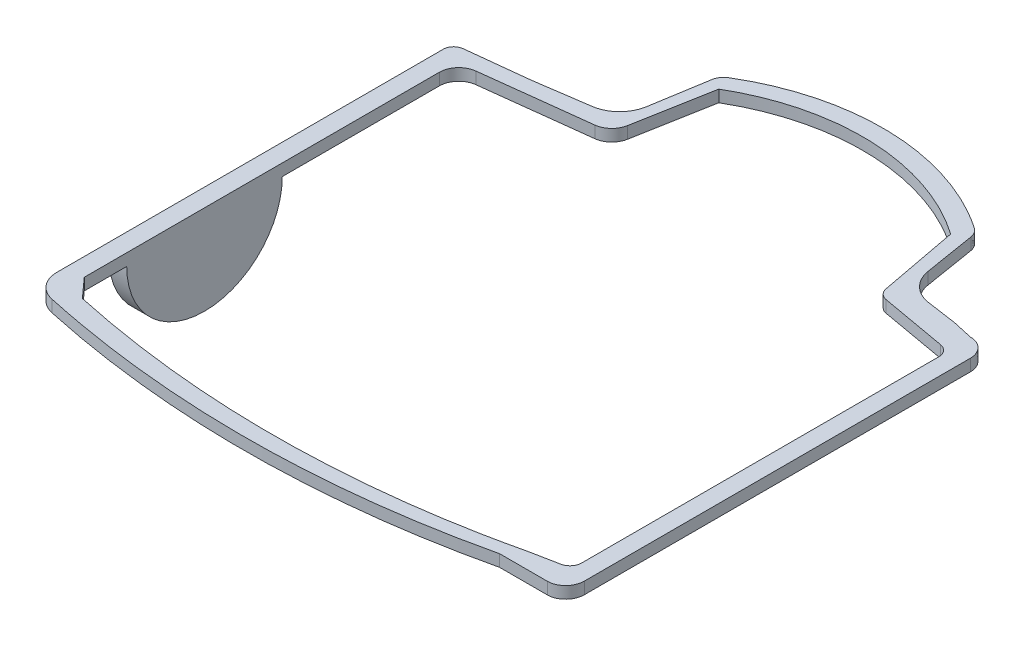
from build123d import *

# Parameters (mm, degrees)
EXTRUDE1_DEPTH    = 3.048
EXTRUDE2_START    = -4.922022
EXTRUDE2_DEPTH    = 4.922022
SKETCH7_OUTSIDE_W = 180.306
SKETCH7_OUTSIDE_H = 194.6
EXTRUDE3_DEPTH    = 66


with BuildPart() as part:
    # Sketch1 → Extrude1 (new body)
    with BuildSketch(Plane(origin=(0, 0, 0), x_dir=(1, 0, 0), z_dir=(0, 1, 0))):
        with BuildLine():
            Line((-68.588225015, -50.447006933), (-68.588225015, -8.447006933))
            Line((-68.588225015, -8.447006933), (-68.588225015, 36.476262533))
            ThreePointArc((-68.588225015, 36.476262533), (-67.823252384, 38.47742536), (-65.918456575, 39.458031658))
            Line((-65.918456575, 39.458031658), (-50.238652077, 41.194573314))
            ThreePointArc((-50.238652077, 41.194573314), (-50.103667096, 41.210697371), (-49.968978913, 41.229137096))
            Line((-49.968978913, 41.229137096), (-36.405212301, 43.204890932))
            add(Edge.make_bspline(
                [(-29.65298493, 49.892180453), (-29.790845033, 49.048800123), (-30.054186091, 48.248422831), (-30.636357931, 47.111997779), (-30.860349594, 46.74871746), (-31.357293164, 46.067804533), (-31.631491773, 45.747658845), (-32.082330248, 45.298656736), (-32.23999217, 45.153607012), (-32.56434492, 44.87828288), (-32.73106827, 44.747841717), (-33.244584245, 44.377712455), (-33.604640908, 44.159088542), (-34.360627861, 43.778810451), (-34.758876947, 43.616878199), (-35.56849202, 43.36152283), (-35.982264945, 43.266499177), (-36.405212301, 43.204890932)],
                knots=[0, 0, 0, 0, 0.25, 0.25, 0.375, 0.375, 0.5, 0.5, 0.5625, 0.5625, 0.625, 0.625, 0.75, 0.75, 0.875, 0.875, 1, 1, 1, 1], degree=3))
            Line((-29.65298493, 49.892180453), (-27.295043857, 64.317246664))
            add(Edge.make_bspline(
                [(-25.398403705, 67.116004585), (-25.649830938, 66.965226012), (-25.880200616, 66.789908757), (-26.300568587, 66.392228876), (-26.492052484, 66.166884769), (-26.817136098, 65.687155628), (-26.952806077, 65.431741016), (-27.169221008, 64.889128082), (-27.24775317, 64.606554695), (-27.295043857, 64.317246664)],
                knots=[0, 0, 0, 0, 0.25, 0.25, 0.5, 0.5, 0.75, 0.75, 1, 1, 1, 1], degree=3))
            add(Edge.make_bspline(
                [(39.946457275, 65.21487163), (37.548346719, 66.848744919), (35.063171769, 68.292658296), (29.92526946, 70.81491379), (27.272527642, 71.893224358), (23.84960363, 73.007663624), (23.159643932, 73.218824356), (21.768814193, 73.617341281), (21.066849207, 73.804928486), (18.960504961, 74.327526345), (17.55147157, 74.623797041), (13.310303393, 75.35995475), (10.464168442, 75.647923544), (6.167019051, 75.776619359), (4.729961072, 75.768790373), (1.846297736, 75.64953214), (0.395242238, 75.53728528), (-3.906620393, 75.048810357), (-6.724065109, 74.522139921), (-12.260788462, 73.077757748), (-14.980069273, 72.160054673), (-18.315815004, 70.760552168), (-18.980393058, 70.46765711), (-20.296101599, 69.859409258), (-20.947996673, 69.543762313), (-22.885867568, 68.562374761), (-24.154051585, 67.862230979), (-25.398403705, 67.116004585)],
                knots=[0, 0, 0, 0, 0.125, 0.125, 0.25, 0.25, 0.28125, 0.28125, 0.3125, 0.3125, 0.375, 0.375, 0.5, 0.5, 0.5625, 0.5625, 0.625, 0.625, 0.75, 0.75, 0.875, 0.875, 0.90625, 0.90625, 0.9375, 0.9375, 1, 1, 1, 1], degree=3))
            add(Edge.make_bspline(
                [(41.64820015, 62.540799755), (41.604039667, 62.810958287), (41.533425164, 63.072041448), (41.341350867, 63.576764675), (41.218012217, 63.823007043), (40.926990246, 64.280858099), (40.760036358, 64.492860302), (40.383155624, 64.882949273), (40.172700886, 65.06072803), (39.946457275, 65.21487163)],
                knots=[0, 0, 0, 0, 0.25, 0.25, 0.5, 0.5, 0.75, 0.75, 1, 1, 1, 1], degree=3))
            Line((41.64820015, 62.540799755), (43.786161784, 49.461491505))
            add(Edge.make_bspline(
                [(50.538389155, 42.774201985), (49.692597751, 42.897403427), (48.889079341, 43.150828046), (47.746268764, 43.723396496), (47.382146665, 43.944235836), (46.69795592, 44.436641493), (46.375910798, 44.709187447), (45.923516022, 45.158306136), (45.777532635, 45.315236658), (45.50087131, 45.637312265), (45.369568312, 45.803013725), (44.996272823, 46.313797506), (44.774768734, 46.672476215), (44.387075083, 47.426541114), (44.221321939, 47.822614875), (43.956171894, 48.627827375), (43.855083908, 49.039849834), (43.786161784, 49.461491505)],
                knots=[0, 0, 0, 0, 0.25, 0.25, 0.375, 0.375, 0.5, 0.5, 0.5625, 0.5625, 0.625, 0.625, 0.75, 0.75, 0.875, 0.875, 1, 1, 1, 1], degree=3))
            Line((50.538389155, 42.774201985), (58.440089637, 41.623207907))
            Line((58.440089637, 41.623207907), (63.588225015, 40.468930958))
            add(Edge.make_bspline(
                [(68.588225015, 35.44224599), (68.588225015, 35.773254316), (68.556021228, 36.098784146), (68.461358552, 36.579192656), (68.422021117, 36.738004749), (68.327424314, 37.052920303), (68.271872128, 37.209534827), (68.084584875, 37.665329204), (67.931722078, 37.953670071), (67.570460552, 38.499570051), (67.359921239, 38.758449119), (66.899556696, 39.222838097), (66.648302998, 39.431296313), (66.102661574, 39.799623667), (65.811118966, 39.956772738), (65.209087651, 40.208769752), (64.894651475, 40.305670054), (64.246771662, 40.436198597), (63.919283432, 40.468930958), (63.588225015, 40.468930958)],
                knots=[0, 0, 0, 0, 0.125, 0.125, 0.1875, 0.1875, 0.25, 0.25, 0.375, 0.375, 0.5, 0.5, 0.625, 0.625, 0.75, 0.75, 0.875, 0.875, 1, 1, 1, 1], degree=3))
            Line((68.588225015, 35.44224599), (68.588218791, -63.754822214))
            add(Edge.make_bspline(
                [(63.588218791, -68.902162312), (63.923306937, -68.902162312), (64.25252025, -68.867855209), (64.899712771, -68.733637518), (65.221180948, -68.631932879), (65.830547879, -68.368331753), (66.119042643, -68.207300566), (66.664058612, -67.827506129), (66.919687763, -67.608228672), (67.377079357, -67.130790475), (67.582113335, -66.870497188), (67.943235276, -66.306577156), (68.093765574, -66.011699483), (68.337870377, -65.39744467), (68.431875057, -65.075082192), (68.556800634, -64.420646043), (68.588218791, -64.089647238), (68.588218791, -63.754822214)],
                knots=[0, 0, 0, 0, 0.125, 0.125, 0.25, 0.25, 0.375, 0.375, 0.5, 0.5, 0.625, 0.625, 0.75, 0.75, 0.875, 0.875, 1, 1, 1, 1], degree=3))
            Line((63.588218791, -68.902162312), (51.32733075, -68.902162312))
            add(Edge.make_bspline(
                [(-63.058226864, -69.750431632), (-53.643280021, -71.800179342), (-44.143561703, -73.319672557), (-24.976642993, -75.311040979), (-15.366883932, -75.776619359), (3.902347458, -75.625508924), (13.476454984, -75.011667248), (32.496305515, -72.745142394), (41.944035583, -71.092627797), (51.32733075, -68.902162312)],
                knots=[0, 0, 0, 0, 0.25, 0.25, 0.5, 0.5, 0.75, 0.75, 1, 1, 1, 1], degree=3))
            add(Edge.make_bspline(
                [(-68.588225015, -62.812922076), (-68.588225015, -63.619702903), (-68.456305975, -64.404084155), (-67.9279771, -65.927936682), (-67.545502278, -66.626025877), (-66.544078761, -67.889406122), (-65.950990154, -68.421382079), (-64.584875646, -69.277063679), (-63.846782984, -69.578753434), (-63.058226864, -69.750431632)],
                knots=[0, 0, 0, 0, 0.25, 0.25, 0.5, 0.5, 0.75, 0.75, 1, 1, 1, 1], degree=3))
            Line((-68.588225015, -62.812922076), (-68.588225015, -50.447006933))
        make_face()
        with BuildLine():
            Line((-63.666203197, -60.439880615), (-63.666203197, -52.176662042))
            Line((-63.666203197, -52.176662042), (-63.666203197, -6.717351825))
            Line((-63.666203197, -6.717351825), (-63.666203197, 30.862484301))
            ThreePointArc((-63.666203197, 30.862484301), (-62.405536347, 34.181729335), (-59.259248158, 35.827189496))
            Line((-59.259248158, 35.827189496), (-31.919097385, 39.093030672))
            ThreePointArc((-31.919097385, 39.093030672), (-29.085376213, 40.416681917), (-27.592483972, 43.165008872))
            Line((-27.592483972, 43.165008872), (-23.987325535, 63.032390503))
            add(Edge.make_bspline(
                [(-23.987325535, 63.032390503), (-22.797133326, 63.729242773), (-21.584758638, 64.38206327), (-19.73306331, 65.295525092), (-19.110304285, 65.589040461), (-17.853691073, 66.154049233), (-17.219092065, 66.425821419), (-15.945235684, 66.9446247), (-15.305425073, 67.191999646), (-14.020083768, 67.662886741), (-13.374553208, 67.886398807), (-11.429450154, 68.521425694), (-10.121366283, 68.897431206), (-7.48286605, 69.556271469), (-6.152449253, 69.839104402), (-4.139838561, 70.192490615), (-3.466137414, 70.298475489), (-2.451309886, 70.439614204), (-2.112321409, 70.483687343), (-1.43291428, 70.565866957), (-1.092495759, 70.603973442), (-0.410223111, 70.674199239), (-0.06809824, 70.706297034), (0.617344562, 70.764409572), (0.960662362, 70.790424325), (1.991227722, 70.859264858), (2.679086985, 70.892886868), (4.050159845, 70.935165523), (4.73442996, 70.944005556), (6.100465355, 70.937342433), (6.782230378, 70.92183922), (10.18485778, 70.784102894), (12.887199026, 70.481908625), (16.240350042, 69.863433501), (16.909736979, 69.727658236), (18.245994002, 69.431652667), (18.912863846, 69.271422459), (20.244057358, 68.926212191), (20.90939076, 68.740879996), (22.22738475, 68.348154347), (22.881076068, 68.140532644), (24.826470511, 67.484389713), (26.102589867, 67.00279619), (28.613650647, 65.952218689), (29.84859206, 65.383234685), (33.492313186, 63.546605715), (35.840002607, 62.149310998), (38.103053994, 60.572391997)],
                knots=[0, 0, 0, 0, 0.0625, 0.0625, 0.09375, 0.09375, 0.125, 0.125, 0.15625, 0.15625, 0.1875, 0.1875, 0.25, 0.25, 0.3125, 0.3125, 0.34375, 0.34375, 0.359375, 0.359375, 0.375, 0.375, 0.390625, 0.390625, 0.40625, 0.40625, 0.4375, 0.4375, 0.46875, 0.46875, 0.5, 0.5, 0.625, 0.625, 0.65625, 0.65625, 0.6875, 0.6875, 0.71875, 0.71875, 0.75, 0.75, 0.8125, 0.8125, 0.875, 0.875, 1, 1, 1, 1], degree=3))
            Line((38.103053994, 60.572391997), (41.989282829, 40.057287174))
            ThreePointArc((41.989282829, 40.057287174), (42.827627821, 38.482317147), (44.412021505, 37.661921165))
            Line((44.412021505, 37.661921165), (61.435143503, 34.637128514))
            ThreePointArc((61.435143503, 34.637128514), (63.209707192, 33.610241672), (63.91030255, 31.683394761))
            Line((63.91030255, 31.683394761), (63.910296789, -60.12270492))
            ThreePointArc((63.910296789, -60.12270492), (63.22803468, -62.02745959), (61.491569593, -63.065853034))
            Line((61.491569593, -63.065853034), (54.228190779, -64.500372852))
            add(Edge.make_bspline(
                [(54.228190779, -64.500372852), (53.646867638, -64.636078726), (53.065379768, -64.770443612), (52.192801078, -64.96916712), (51.9018837, -65.034937653), (51.465408439, -65.132785955), (51.319900153, -65.165267472), (51.028848437, -65.229944419), (50.883305004, -65.262139823), (50.592180927, -65.326227715), (50.446602916, -65.358141641), (50.155414986, -65.421709735), (50.009805064, -65.453363879), (49.572927449, -65.547936812), (49.281611909, -65.610466098), (48.407474105, -65.796497612), (47.824460655, -65.918443491), (44.908121552, -66.517819345), (42.570980339, -66.964188687), (35.547451567, -68.204754667), (30.848958746, -68.900408211), (21.420254, -70.033505383), (16.690042075, -70.47094901), (9.570501221, -70.929926983), (7.19328364, -71.050053101), (2.430697569, -71.223956158), (0.043817097, -71.277740334), (-7.118289251, -71.338556455), (-11.887166083, -71.244653595), (-21.413307491, -70.790490202), (-26.171888338, -70.43010405), (-40.422184613, -68.954109584), (-49.839764859, -67.449410248), (-59.173660294, -65.417308409)],
                knots=[0, 0, 0, 0, 0.015625, 0.015625, 0.0234375, 0.0234375, 0.02734375, 0.02734375, 0.03125, 0.03125, 0.03515625, 0.03515625, 0.0390625, 0.0390625, 0.046875, 0.046875, 0.0625, 0.0625, 0.125, 0.125, 0.25, 0.25, 0.375, 0.375, 0.4375, 0.4375, 0.5, 0.5, 0.625, 0.625, 0.75, 0.75, 1, 1, 1, 1], degree=3))
            Line((-59.173660294, -65.417308409), (-63.666203197, -60.439880615))
        make_face(mode=Mode.SUBTRACT)
    extrude(amount=EXTRUDE1_DEPTH)

    # Sketch5 → Extrude2 (add)
    with BuildSketch(Plane.ZY.offset(68.588225015).offset(EXTRUDE2_START)):
        with BuildLine():
            Line((9.73548029, 2.872755472), (49.320693489, 2.872755472))
            ThreePointArc((49.320693489, 2.872755472), (29.52808689, -20), (9.73548029, 2.872755472))
        make_face()
    extrude(amount=EXTRUDE2_DEPTH)

    # Sketch7 outside → Extrude3 (cut)
    with BuildSketch(Plane(origin=(0, 3.048, 0), x_dir=(1, 0, 0), z_dir=(0, 1, 0))):
        with Locations((0, 0.026)):
            Rectangle(SKETCH7_OUTSIDE_W, SKETCH7_OUTSIDE_H)
        with BuildLine():
            Line((-68.288225015, 36.476262533), (-68.288225015, -62.812922076))
            add(Edge.make_bspline(
                [(-68.288225015, -62.812922076), (-68.288225015, -63.58548994), (-68.161995647, -64.336613523), (-67.656432045, -65.795862362), (-67.290363007, -66.464531085), (-66.331952793, -67.674488228), (-65.764084112, -68.184220334), (-64.456367134, -69.003806509), (-63.749461721, -69.292913976), (-62.994408185, -69.457298256)],
                knots=[0, 0, 0, 0, 0.25, 0.25, 0.5, 0.5, 0.75, 0.75, 1, 1, 1, 1], degree=3))
            add(Edge.make_bspline(
                [(-62.994408185, -69.457298256), (-53.587469101, -71.50530258), (-44.095802438, -73.023340729), (-24.9450763, -75.012384547), (-15.343518571, -75.477081083), (3.90939398, -75.324789065), (13.475061408, -74.710662751), (32.478327648, -72.444207561), (41.917615146, -70.790729546), (51.292778774, -68.602162312)],
                knots=[0, 0, 0, 0, 0.25, 0.25, 0.5, 0.5, 0.75, 0.75, 1, 1, 1, 1], degree=3))
            Line((51.292778774, -68.602162312), (63.588218791, -68.602162312))
            add(Edge.make_bspline(
                [(63.588218791, -68.602162312), (63.903508853, -68.602162312), (64.213252696, -68.569795452), (64.82213345, -68.443161347), (65.124585087, -68.347192936), (65.697570513, -68.098643571), (65.968813193, -67.946827933), (66.481172228, -67.588789711), (66.721370661, -67.382177093), (67.15112973, -66.932368718), (67.34390324, -66.686913379), (67.682856497, -66.15613609), (67.824162467, -65.878579118), (68.053306363, -65.300369631), (68.14155395, -64.99686513), (68.258742615, -64.381223934), (68.288218791, -64.069831136), (68.288218791, -63.754822214)],
                knots=[0, 0, 0, 0, 0.125, 0.125, 0.25, 0.25, 0.375, 0.375, 0.5, 0.5, 0.625, 0.625, 0.75, 0.75, 0.875, 0.875, 1, 1, 1, 1], degree=3))
            Line((68.288218791, -63.754822214), (68.288225015, 35.442246009))
            add(Edge.make_bspline(
                [(68.288225015, 35.442246009), (68.288225014, 35.754829729), (68.257695957, 36.062220708), (68.138039329, 36.667035542), (68.047466981, 36.967575783), (67.810807597, 37.541002957), (67.665947182, 37.813011639), (67.323478471, 38.327792995), (67.123960266, 38.571720945), (66.687896308, 39.00878617), (66.449882941, 39.204816339), (65.932832725, 39.550677259), (65.657097086, 39.697658531), (65.087320787, 39.932749147), (64.78930767, 40.022718961), (64.177053113, 40.142184042), (63.867441834, 40.168930958), (63.555005499, 40.168930958)],
                knots=[0, 0, 0, 0, 0.125, 0.125, 0.25, 0.25, 0.375, 0.375, 0.5, 0.5, 0.625, 0.625, 0.75, 0.75, 0.875, 0.875, 1, 1, 1, 1], degree=3))
            Line((63.555005499, 40.168930958), (58.385572557, 41.32798309))
            Line((58.385572557, 41.32798309), (50.495146282, 42.47733492))
            add(Edge.make_bspline(
                [(50.495146282, 42.47733492), (49.61783392, 42.605127834), (48.784327631, 42.867916183), (47.59882174, 43.461647126), (47.221077381, 43.690649538), (46.511265357, 44.201275912), (46.177146613, 44.483915151), (45.707776004, 44.949686788), (45.556309757, 45.112441572), (45.269262239, 45.44646375), (45.133028613, 45.6183148), (44.745709609, 46.1480635), (44.515876987, 46.520070976), (44.113602416, 47.302187926), (43.94159594, 47.713050434), (43.666470689, 48.548302327), (43.561587618, 48.975704823), (43.490091156, 49.413095395)],
                knots=[0, 0, 0, 0, 0.25, 0.25, 0.375, 0.375, 0.5, 0.5, 0.5625, 0.5625, 0.625, 0.625, 0.75, 0.75, 0.875, 0.875, 1, 1, 1, 1], degree=3))
            Line((43.490091156, 49.413095395), (41.352129522, 62.492403645))
            add(Edge.make_bspline(
                [(41.352129522, 62.492403645), (41.311330759, 62.74199634), (41.245936279, 62.984456251), (41.066434328, 63.455249258), (40.952830159, 63.681016355), (40.685272049, 64.101829783), (40.529493874, 64.299966016), (40.178720706, 64.662537815), (39.986597823, 64.824511699), (39.777541075, 64.966945598)],
                knots=[0, 0, 0, 0, 0.25, 0.25, 0.5, 0.5, 0.75, 0.75, 1, 1, 1, 1], degree=3))
            add(Edge.make_bspline(
                [(39.777541075, 64.966945598), (37.391302354, 66.592730405), (34.918423582, 68.029508066), (29.80592367, 70.539311301), (27.16628829, 71.612305808), (23.760261014, 72.721253861), (23.073706479, 72.93137434), (21.689739356, 73.327928216), (20.991245422, 73.514589047), (18.895361493, 74.0345964), (17.493317712, 74.329401573), (13.273164905, 75.061922994), (10.441102033, 75.348477645), (6.165151305, 75.476541887), (4.735174699, 75.468751624), (1.865704719, 75.350076222), (0.421799389, 75.23837659), (-3.858640645, 74.752323427), (-6.662100025, 74.22826781), (-12.171420971, 72.791028043), (-14.877284765, 71.877852776), (-18.196620895, 70.485224251), (-18.8579156, 70.193773498), (-20.167095074, 69.588539797), (-20.815756566, 69.274456809), (-22.744019115, 68.297930902), (-24.005920633, 67.601254351), (-25.244113495, 66.858721607)],
                knots=[0, 0, 0, 0, 0.125, 0.125, 0.25, 0.25, 0.28125, 0.28125, 0.3125, 0.3125, 0.375, 0.375, 0.5, 0.5, 0.5625, 0.5625, 0.625, 0.625, 0.75, 0.75, 0.875, 0.875, 0.90625, 0.90625, 0.9375, 0.9375, 1, 1, 1, 1], degree=3))
            add(Edge.make_bspline(
                [(-25.244113495, 66.858721607), (-25.476561377, 66.719324774), (-25.690672988, 66.556581721), (-26.08270128, 66.185011278), (-26.257372852, 65.978631122), (-26.557001909, 65.536040007), (-26.684470749, 65.295549234), (-26.883385181, 64.795163266), (-26.955242086, 64.536382531), (-26.998973229, 64.268850554)],
                knots=[0, 0, 0, 0, 0.25, 0.25, 0.5, 0.5, 0.75, 0.75, 1, 1, 1, 1], degree=3))
            Line((-26.998973229, 64.268850554), (-29.356914302, 49.843784343))
            add(Edge.make_bspline(
                [(-29.356914302, 49.843784343), (-29.49991498, 48.968955759), (-29.773143438, 48.138773652), (-30.276507465, 47.15652627), (-30.385564955, 46.963045971), (-30.616347796, 46.588584163), (-30.73851032, 46.406701767), (-31.12522433, 45.877031481), (-31.409720704, 45.5449981), (-31.877474522, 45.079341321), (-32.041052351, 44.928910137), (-32.377564809, 44.643381), (-32.550534928, 44.508108385), (-33.083277822, 44.12427509), (-33.45679949, 43.897566016), (-34.241019009, 43.503233312), (-34.654165284, 43.335298605), (-35.494021937, 43.070480662), (-35.923242142, 42.971930682), (-36.361969428, 42.908023867)],
                knots=[0, 0, 0, 0, 0.25, 0.25, 0.3125, 0.3125, 0.375, 0.375, 0.5, 0.5, 0.5625, 0.5625, 0.625, 0.625, 0.75, 0.75, 0.875, 0.875, 1, 1, 1, 1], degree=3))
            Line((-36.361969428, 42.908023867), (-49.92573604, 40.932270032))
            ThreePointArc((-49.92573604, 40.932270032), (-50.065528458, 40.913131506), (-50.205628921, 40.896396402))
            Line((-50.205628921, 40.896396402), (-65.885433419, 39.159854746))
            ThreePointArc((-65.885433419, 39.159854746), (-67.599749647, 38.277309077), (-68.288225015, 36.476262533))
        make_face(mode=Mode.SUBTRACT)
    extrude(amount=-EXTRUDE3_DEPTH, mode=Mode.SUBTRACT)


solid = part.part
